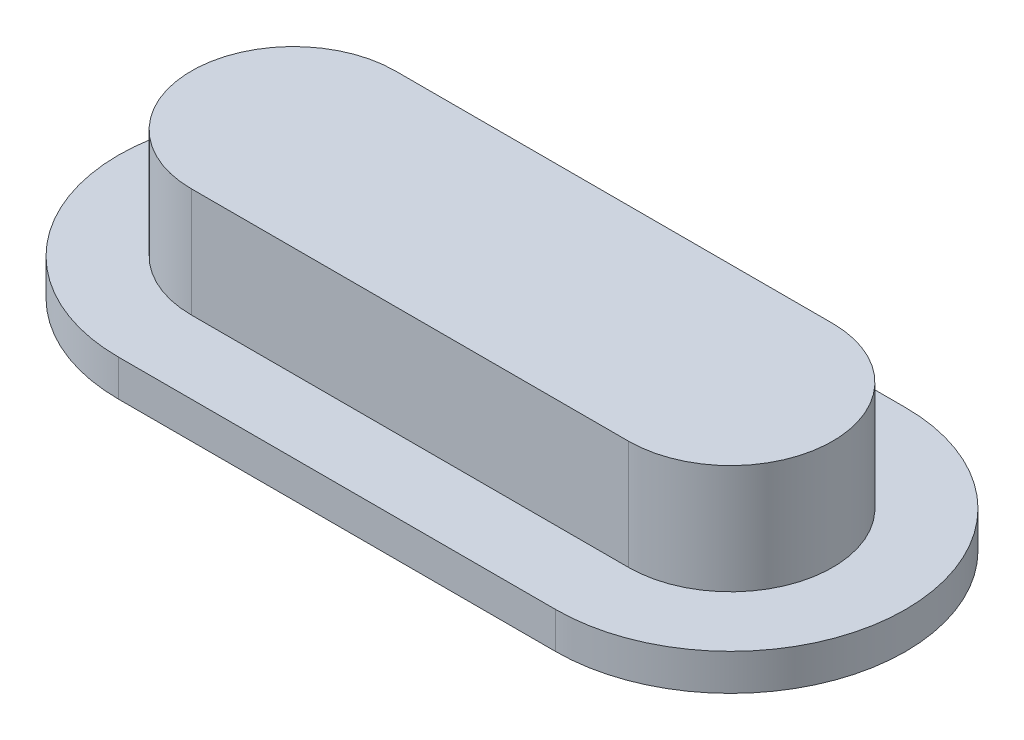
from build123d import *

# Parameters (mm, degrees)
EXTRUDE_1_DEPTH = 1.5
EXTRUDE_2_DEPTH = 0.5


with BuildPart() as part:
    # 草图1 → 凸台-拉伸1 (new body)
    with BuildSketch(Plane(origin=(0, 0, 0), x_dir=(1, 0, 0), z_dir=(0, 1, 0))):
        with BuildLine():
            Line((-3, 1.4), (3, 1.4))
            ThreePointArc((3, 1.4), (4.4, 0), (3, -1.4))
            Line((3, -1.4), (-3, -1.4))
            ThreePointArc((-3, -1.4), (-4.4, 0), (-3, 1.4))
        make_face()
    extrude(amount=EXTRUDE_1_DEPTH)

    # 草图2 → 凸台-拉伸2 (add)
    with BuildSketch(Plane.XZ):
        with BuildLine():
            Line((-3, -2.4), (3, -2.4))
            ThreePointArc((3, -2.4), (5.4, 0), (3, 2.4))
            Line((3, 2.4), (-3, 2.4))
            ThreePointArc((-3, 2.4), (-5.4, 0), (-3, -2.4))
        make_face()
    extrude(amount=EXTRUDE_2_DEPTH)


solid = part.part
